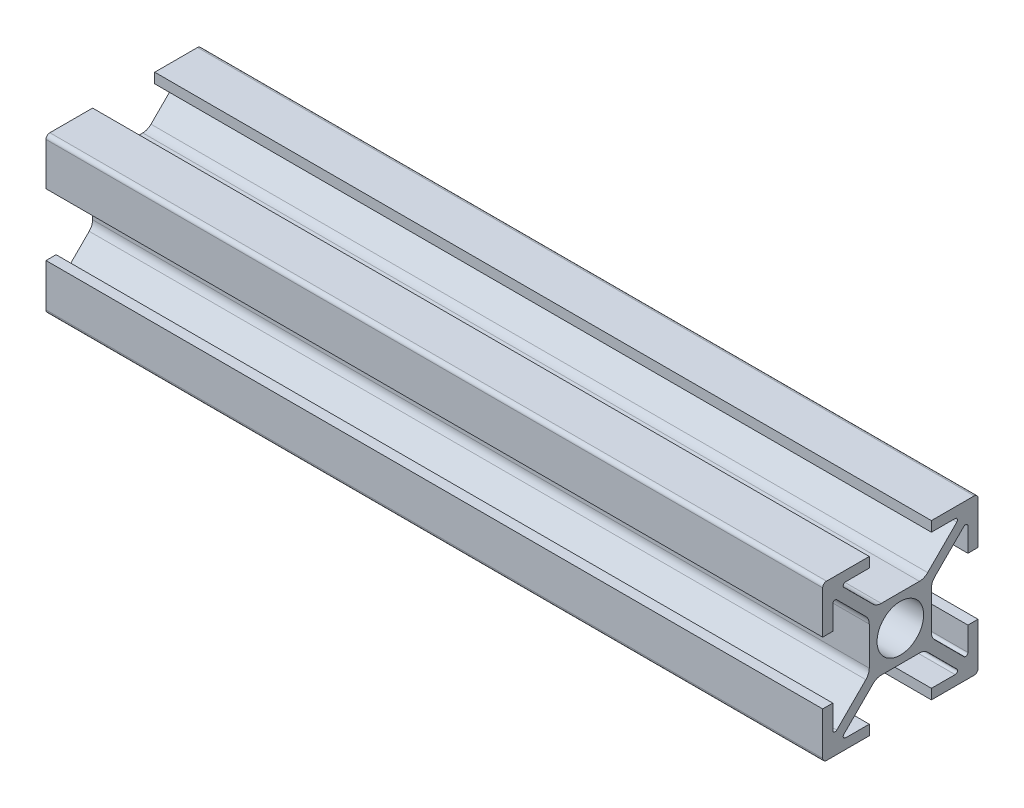
from build123d import *

# Parameters (mm, degrees)
SKETCH1_R                                   = 3
QUADRADO_PF20_01_PERFIL_2020_B_SICO_1_DEPTH = 100


with BuildPart() as part:
    # Sketch1 → Quadrado PF20-01 - PERFIL 2020 BÁSICO(1) (new body)
    with BuildSketch(Plane.YZ):
        with BuildLine():
            Line((8.187867966, -7.26862915), (4.439339828, -3.520101013))
            ThreePointArc((4.439339828, -3.520101013), (4.114180701, -3.033465989), (4, -2.459440841))
            Line((4, -2.459440841), (4, 2.459440841))
            ThreePointArc((4, 2.459440841), (4.114180701, 3.033465989), (4.439339828, 3.520101013))
            Line((4.439339828, 3.520101013), (8.187867966, 7.26862915))
            ThreePointArc((8.187867966, 7.26862915), (8.51480503, 7.333660975), (8.7, 7.056497116))
            Line((8.7, 7.056497116), (8.7, 4))
            Line((8.7, 4), (10, 4))
            Line((10, 4), (10, 9.5))
            ThreePointArc((10, 9.5), (9.853553391, 9.853553391), (9.5, 10))
            Line((9.5, 10), (4, 10))
            Line((4, 10), (4, 8.7))
            Line((4, 8.7), (7.056497116, 8.7))
            ThreePointArc((7.056497116, 8.7), (7.333660975, 8.51480503), (7.26862915, 8.187867966))
            Line((7.26862915, 8.187867966), (3.520101013, 4.439339828))
            ThreePointArc((3.520101013, 4.439339828), (3.033465989, 4.114180701), (2.459440841, 4))
            Line((2.459440841, 4), (-2.459440841, 4))
            ThreePointArc((-2.459440841, 4), (-3.033465989, 4.114180701), (-3.520101013, 4.439339828))
            Line((-3.520101013, 4.439339828), (-7.26862915, 8.187867966))
            ThreePointArc((-7.26862915, 8.187867966), (-7.333660975, 8.51480503), (-7.056497116, 8.7))
            Line((-7.056497116, 8.7), (-4, 8.7))
            Line((-4, 8.7), (-4, 10))
            Line((-4, 10), (-9.5, 10))
            ThreePointArc((-9.5, 10), (-9.853553391, 9.853553391), (-10, 9.5))
            Line((-10, 9.5), (-10, 4))
            Line((-10, 4), (-8.7, 4))
            Line((-8.7, 4), (-8.7, 7.056497116))
            ThreePointArc((-8.7, 7.056497116), (-8.51480503, 7.333660975), (-8.187867966, 7.26862915))
            Line((-8.187867966, 7.26862915), (-4.439339828, 3.520101013))
            ThreePointArc((-4.439339828, 3.520101013), (-4.114180701, 3.033465989), (-4, 2.459440841))
            Line((-4, 2.459440841), (-4, -2.459440841))
            ThreePointArc((-4, -2.459440841), (-4.114180701, -3.033465989), (-4.439339828, -3.520101013))
            Line((-4.439339828, -3.520101013), (-8.187867966, -7.26862915))
            ThreePointArc((-8.187867966, -7.26862915), (-8.51480503, -7.333660975), (-8.7, -7.056497116))
            Line((-8.7, -7.056497116), (-8.7, -4))
            Line((-8.7, -4), (-10, -4))
            Line((-10, -4), (-10, -9.5))
            ThreePointArc((-10, -9.5), (-9.853553391, -9.853553391), (-9.5, -10))
            Line((-9.5, -10), (-4, -10))
            Line((-4, -10), (-4, -8.7))
            Line((-4, -8.7), (-7.056497116, -8.7))
            ThreePointArc((-7.056497116, -8.7), (-7.333660975, -8.51480503), (-7.26862915, -8.187867966))
            Line((-7.26862915, -8.187867966), (-3.520101013, -4.439339828))
            ThreePointArc((-3.520101013, -4.439339828), (-3.033465989, -4.114180701), (-2.459440841, -4))
            Line((-2.459440841, -4), (2.459440841, -4))
            ThreePointArc((2.459440841, -4), (3.033465989, -4.114180701), (3.520101013, -4.439339828))
            Line((3.520101013, -4.439339828), (7.26862915, -8.187867966))
            ThreePointArc((7.26862915, -8.187867966), (7.333660975, -8.51480503), (7.056497116, -8.7))
            Line((7.056497116, -8.7), (4, -8.7))
            Line((4, -8.7), (4, -10))
            Line((4, -10), (9.5, -10))
            ThreePointArc((9.5, -10), (9.853553391, -9.853553391), (10, -9.5))
            Line((10, -9.5), (10, -4))
            Line((10, -4), (8.7, -4))
            Line((8.7, -4), (8.7, -7.056497116))
            ThreePointArc((8.7, -7.056497116), (8.51480503, -7.333660975), (8.187867966, -7.26862915))
        make_face()
        Circle(SKETCH1_R, mode=Mode.SUBTRACT)
    extrude(amount=QUADRADO_PF20_01_PERFIL_2020_B_SICO_1_DEPTH)


solid = part.part
